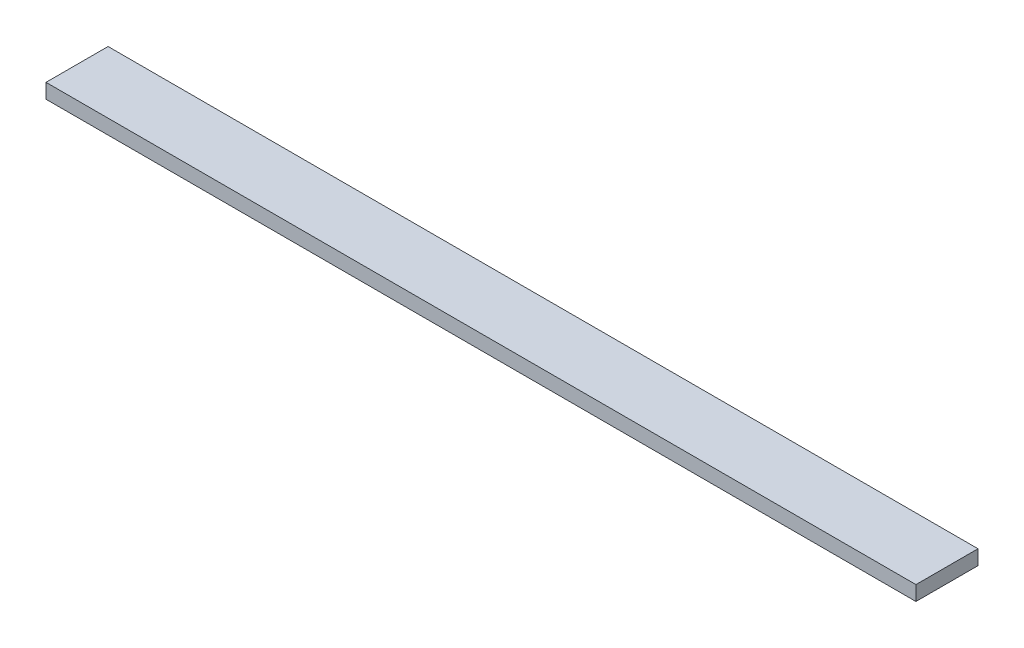
from build123d import *

# Parameters (mm, degrees)
SKETCH1_W           = 178
SKETCH1_H           = 12.7
BOSS_EXTRUDE1_DEPTH = 3


with BuildPart() as part:
    # Sketch1 → Boss-Extrude1 (new body)
    with BuildSketch(Plane(origin=(0, 0, 0), x_dir=(1, 0, 0), z_dir=(0, 1, 0))):
        with Locations((89, 6.35)):
            Rectangle(SKETCH1_W, SKETCH1_H)
    extrude(amount=BOSS_EXTRUDE1_DEPTH)


solid = part.part
